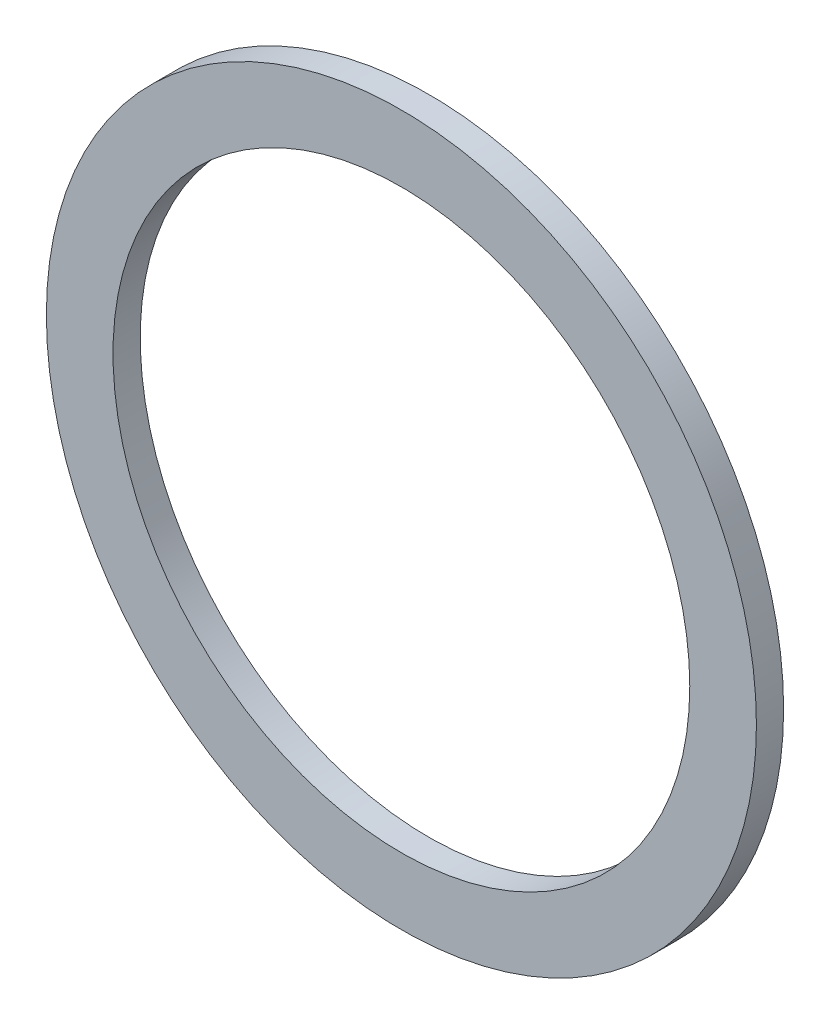
from build123d import *

# Parameters (mm, degrees)
SKICA1_R                = 13.05
SKICA1_R_2              = 10.6
P_IDAT_VYSUNUT_M1_DEPTH = 1


with BuildPart() as part:
    # Skica1 → Přidat vysunutím1 (new body)
    with BuildSketch(Plane.XY):
        Circle(SKICA1_R)
        Circle(SKICA1_R_2, mode=Mode.SUBTRACT)
    extrude(amount=P_IDAT_VYSUNUT_M1_DEPTH)


solid = part.part
